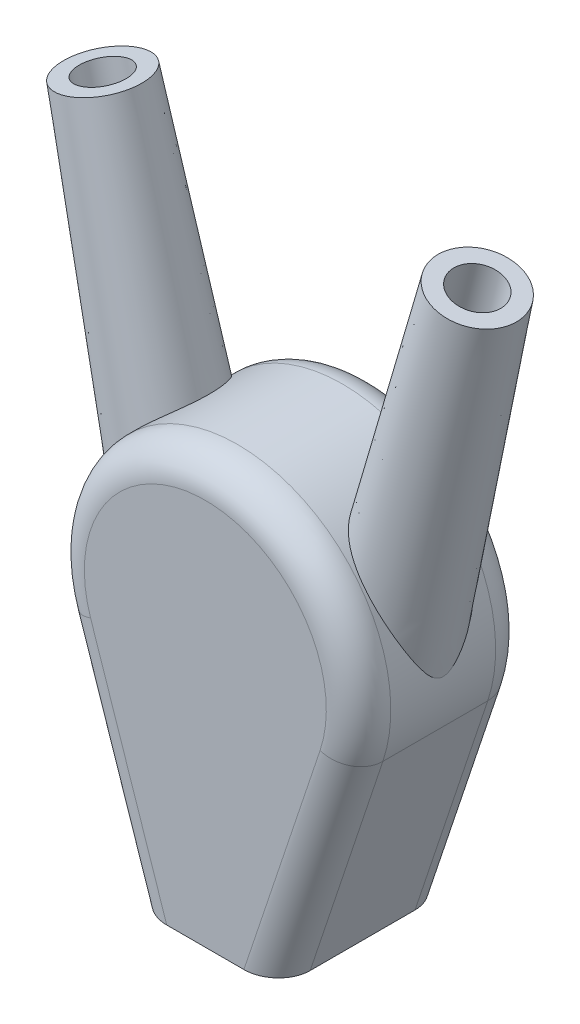
from build123d import *

# Parameters (mm, degrees)
EXTRUSION1_DEPTH        = 5.25
CONG_1_R                = 2
ENL_V_MAT_EXTRU_1_DEPTH = 2.5


with BuildPart() as part:
    # Esquisse1 → Extrusion1 (new body, symmetric)
    with BuildSketch(Plane.XY):
        with BuildLine():
            Line((4.5, 8), (-4.5, 8))
            Line((-4.5, 8), (-9.009706909, 21.487495824))
            ThreePointArc((-9.009706909, 21.487495824), (0, 34), (9.009706909, 21.487495824))
            Line((9.009706909, 21.487495824), (4.5, 8))
        make_face()
    extrude(amount=EXTRUSION1_DEPTH, both=True)

    # Congé1
    cong_1_edges = [part.edges().sort_by_distance(p)[0] for p in [
        (6.754853455, 14.743747912, 5.25),
        (0, 34, 5.25),
        (-6.754853455, 14.743747912, 5.25),
        (0, 34, -5.25),
        (6.754853455, 14.743747912, -5.25),
        (-6.754853455, 14.743747912, -5.25),
    ]]
    fillet(cong_1_edges, radius=CONG_1_R)

    # Esquisse3 → Révolution2 (revolve)
    with BuildSketch(Plane.XY, mode=Mode.PRIVATE) as r_volution2_sk:
        Polygon((-13.067694578, 46.211312018), (-9.438866144, 31.656876124), (-7.983422555, 32.019758967), (-6.345144878, 25.448986095), (-9.498605988, 24.662739935), (-14.037990304, 45.969390122), align=None)
    r_volution2 = revolve(r_volution2_sk.sketch.rotate(Axis((0, 0, 0), (-0.241921896, 0.970295726, 0)), 180), axis=Axis((0, 0, 0), (-0.241921896, 0.970295726, 0)))  # turned: the seam where the file's is

    # Symétrie1: Révolution2 across plane
    add(r_volution2.mirror(Plane(origin=(0, 0, 0), x_dir=(0, 0, 1), z_dir=(1, 0, 0))))

    # Esquisse5 → Enlèv. mat.-Extru.1 (cut, symmetric)
    with BuildSketch(Plane(origin=(0, 0, 0), x_dir=(0, 0, -1), z_dir=(1, 0, 0))):
        with BuildLine():
            Line((-3.25, 8), (3.25, 8))
            Line((3.25, 8), (3.25, 10))
            Line((3.25, 10), (2.291287847, 10))
            ThreePointArc((2.291287847, 10), (0, 13.5), (-2.291287847, 10))
            Line((-2.291287847, 10), (-3.25, 10))
            Line((-3.25, 10), (-3.25, 8))
        make_face()
    extrude(amount=ENL_V_MAT_EXTRU_1_DEPTH, both=True, mode=Mode.SUBTRACT)


solid = part.part
